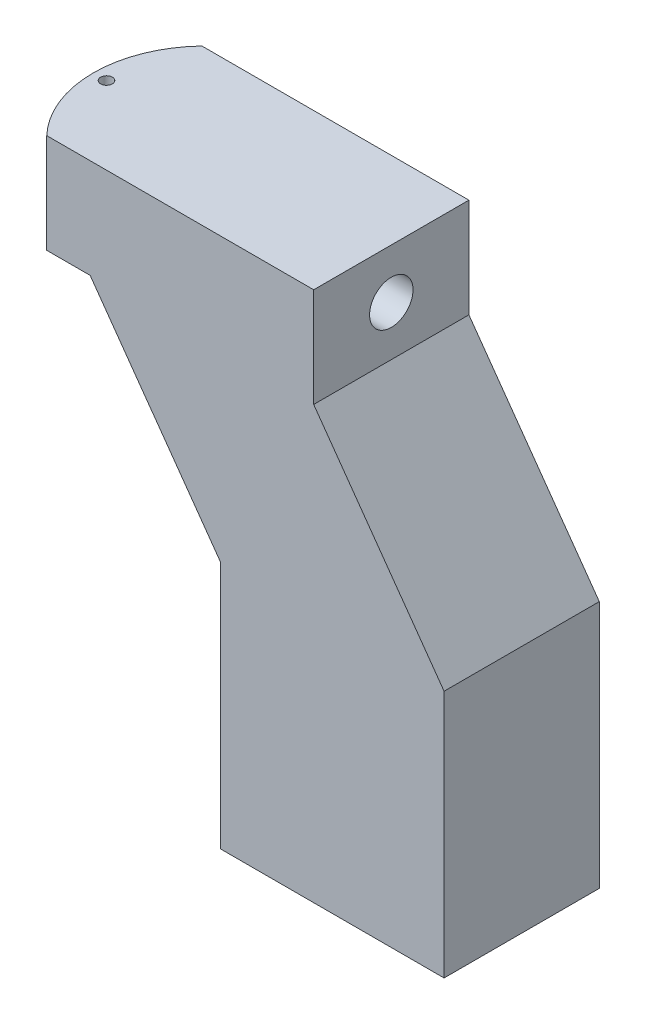
from build123d import *

# Parameters (mm, degrees)
BOSS_EXTRUDE1_DEPTH   = 6.35
CUT_EXTRUDE1_DEPTH    = 6.35
SKETCH5_R             = 1.5875
CUT_EXTRUDE4_DEPTH    = 7.62
SKETCH7_R             = 0.24003
CUT_EXTRUDE5_DEPTH    = 22.717
F_2_56_TAPPED_HOLE1_D = 1.778


with BuildPart() as part:
    # Sketch1 → Boss-Extrude1 (new body)
    with BuildSketch(Plane.XY):
        Polygon((0, 0), (12.192, 0), (12.192, -4.064), (17.526, -11.557), (17.526, -21.717), (8.382, -21.717), (8.382, -11.557), (3.048, -4.064), (0, -4.064), align=None)
    extrude(amount=-BOSS_EXTRUDE1_DEPTH)

    # Sketch2 → Cut-Extrude1 (cut)
    with BuildSketch(Plane(origin=(0, 0, 0), x_dir=(1, 0, 0), z_dir=(0, 1, 0))):
        with BuildLine():
            Line((1.27, 6.35), (-1.332869865, 6.35))
            Line((-1.332869865, 6.35), (-1.332869865, 0))
            Line((-1.332869865, 0), (1.27, 0))
            ThreePointArc((1.27, 0), (0, 3.175), (1.27, 6.35))
        make_face()
    extrude(amount=-CUT_EXTRUDE1_DEPTH, mode=Mode.SUBTRACT)

    # Sketch5 → Cut-Extrude4 (cut)
    with BuildSketch(Plane.XZ.offset(21.717)):
        with Locations((12.954, -3.175)):
            Circle(SKETCH5_R)
    extrude(amount=-CUT_EXTRUDE4_DEPTH, mode=Mode.SUBTRACT)

    # Sketch7 → Cut-Extrude5 (cut, through all)
    with BuildSketch(Plane(origin=(0, 0, 0), x_dir=(1, 0, 0), z_dir=(0, 1, 0))):
        with Locations((0.54102, 3.175)):
            Circle(SKETCH7_R)
    extrude(amount=-CUT_EXTRUDE5_DEPTH, mode=Mode.SUBTRACT)

    # #2-56 Tapped Hole1 (through all)
    with Locations(Plane(origin=(12.192, 0, 0), x_dir=(0, 0, -1), z_dir=(1, 0, 0))):
        with Locations((3.175, -2.032)):
            Hole(F_2_56_TAPPED_HOLE1_D / 2)


solid = part.part
